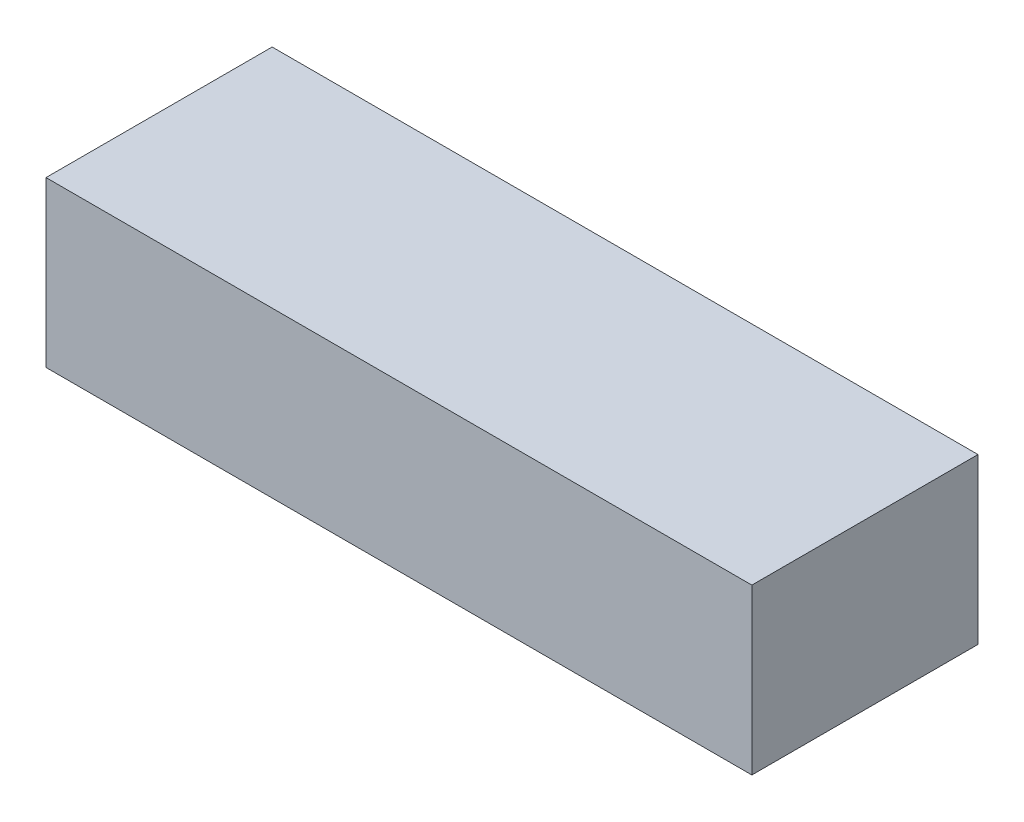
from build123d import *

# Parameters (mm, degrees)
SKETCH1_W           = 103
SKETCH1_H           = 33
BOSS_EXTRUDE1_DEPTH = 24


with BuildPart() as part:
    # Sketch1 → Boss-Extrude1 (new body)
    with BuildSketch(Plane(origin=(0, 0, 0), x_dir=(1, 0, 0), z_dir=(0, 1, 0))):
        Rectangle(SKETCH1_W, SKETCH1_H)
    extrude(amount=BOSS_EXTRUDE1_DEPTH)


solid = part.part
